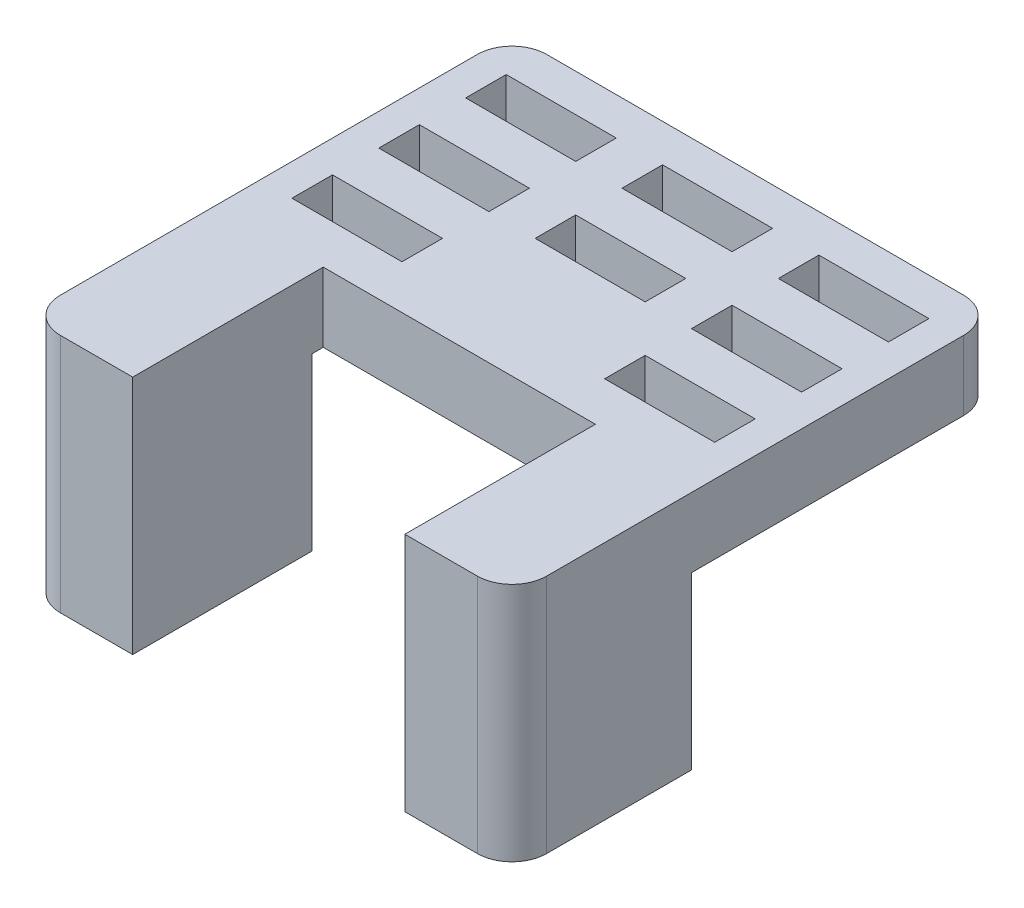
from build123d import *

# Parameters (mm, degrees)
SKETCH1_W            = 44
SKETCH1_H            = 44
BOSS_EXTRUDE1_DEPTH  = 6
CUT_EXTRUDE1_DEPTH   = 7
SKETCH4_W            = 44
SKETCH4_H            = 16.5
BOSS_EXTRUDE2_DEPTH  = 14.75
SKETCH5_W            = 23.5
SKETCH5_H            = 17.45
CUT_EXTRUDE2_DEPTH   = 21.75
FILLET1_R            = 3
SKETCH6_W            = 9.5
SKETCH6_H            = 3.5
CUT_EXTRUDE3_DEPTH   = 3.52
LPATTERN1_COUNT      = 3
LPATTERN1_PITCH      = 13.5
LPATTERN1_COUNT_DIR2 = 3
LPATTERN1_PITCH_DIR2 = 7.5
CUT_EXTRUDE5_REACH   = 22.75


with BuildPart() as part:
    # Sketch1 → Boss-Extrude1 (new body)
    with BuildSketch(Plane(origin=(0, 0, 0), x_dir=(1, 0, 0), z_dir=(0, 1, 0))):
        with Locations((22, 22)):
            Rectangle(SKETCH1_W, SKETCH1_H)
    extrude(amount=-BOSS_EXTRUDE1_DEPTH)

    # Sketch2 → Cut-Extrude1 (cut, through all)
    with BuildSketch(Plane(origin=(0, 0, 0), x_dir=(1, 0, 0), z_dir=(0, 1, 0))):
        with BuildLine():
            Line((5.475, 39.275), (11.525, 39.275))
            ThreePointArc((11.525, 39.275), (12.8, 38), (11.525, 36.725))
            Line((11.525, 36.725), (5.475, 36.725))
            ThreePointArc((5.475, 36.725), (4.2, 38), (5.475, 39.275))
        make_face()
        with BuildLine():
            Line((18.975, 39.275), (25.025, 39.275))
            ThreePointArc((25.025, 39.275), (26.3, 38), (25.025, 36.725))
            Line((25.025, 36.725), (18.975, 36.725))
            ThreePointArc((18.975, 36.725), (17.7, 38), (18.975, 39.275))
        make_face()
        with BuildLine():
            Line((32.475, 39.275), (38.525, 39.275))
            ThreePointArc((38.525, 39.275), (39.8, 38), (38.525, 36.725))
            Line((38.525, 36.725), (32.475, 36.725))
            ThreePointArc((32.475, 36.725), (31.2, 38), (32.475, 39.275))
        make_face()
        with BuildLine():
            Line((18.975, 31.775), (25.025, 31.775))
            ThreePointArc((25.025, 31.775), (26.3, 30.5), (25.025, 29.225))
            Line((25.025, 29.225), (18.975, 29.225))
            ThreePointArc((18.975, 29.225), (17.7, 30.5), (18.975, 31.775))
        make_face()
        with BuildLine():
            Line((32.475, 31.775), (38.525, 31.775))
            ThreePointArc((38.525, 31.775), (39.8, 30.5), (38.525, 29.225))
            Line((38.525, 29.225), (32.475, 29.225))
            ThreePointArc((32.475, 29.225), (31.2, 30.5), (32.475, 31.775))
        make_face()
        with BuildLine():
            Line((32.475, 24.275), (38.525, 24.275))
            ThreePointArc((38.525, 24.275), (39.8, 23), (38.525, 21.725))
            Line((38.525, 21.725), (32.475, 21.725))
            ThreePointArc((32.475, 21.725), (31.2, 23), (32.475, 24.275))
        make_face()
        with BuildLine():
            Line((5.475, 31.775), (11.525, 31.775))
            ThreePointArc((11.525, 31.775), (12.8, 30.5), (11.525, 29.225))
            Line((11.525, 29.225), (5.475, 29.225))
            ThreePointArc((5.475, 29.225), (4.2, 30.5), (5.475, 31.775))
        make_face()
        with BuildLine():
            Line((5.475, 24.275), (11.525, 24.275))
            ThreePointArc((11.525, 24.275), (12.8, 23), (11.525, 21.725))
            Line((11.525, 21.725), (5.475, 21.725))
            ThreePointArc((5.475, 21.725), (4.2, 23), (5.475, 24.275))
        make_face()
    extrude(amount=-CUT_EXTRUDE1_DEPTH, mode=Mode.SUBTRACT)

    # Sketch4 → Boss-Extrude2 (add)
    with BuildSketch(Plane.XZ.offset(6)):
        with Locations((22, -8.25)):
            Rectangle(SKETCH4_W, SKETCH4_H)
    extrude(amount=BOSS_EXTRUDE2_DEPTH)

    # Sketch5 → Cut-Extrude2 (cut, through all)
    with BuildSketch(Plane(origin=(0, 0, 0), x_dir=(1, 0, 0), z_dir=(0, 1, 0))):
        with Locations((22, 8.725)):
            Rectangle(SKETCH5_W, SKETCH5_H)
    extrude(amount=-CUT_EXTRUDE2_DEPTH, mode=Mode.SUBTRACT)

    # Fillet1
    fillet1_edges = [part.edges().sort_by_distance(p)[0] for p in [
        (0, -10.375, 0),
        (44, -10.375, 0),
        (44, -3, -44),
        (0, -3, -44),
    ]]
    fillet(fillet1_edges, radius=FILLET1_R)

    # Sketch6 → Cut-Extrude3 (cut)
    with BuildSketch(Plane(origin=(0, 0, 0), x_dir=(1, 0, 0), z_dir=(0, 1, 0))):
        with Locations((8.5, 38)):
            Rectangle(SKETCH6_W, SKETCH6_H)
    cut_extrude3 = extrude(amount=-CUT_EXTRUDE3_DEPTH, mode=Mode.SUBTRACT)

    # LPattern1: Cut-Extrude3 3 × 3, 1 skipped
    with Locations(*[(i * LPATTERN1_PITCH, 0, j * LPATTERN1_PITCH_DIR2) for i in range(LPATTERN1_COUNT) for j in range(LPATTERN1_COUNT_DIR2) if (i, j) not in ((0, 0), (1, 2))]):
        add(cut_extrude3, mode=Mode.SUBTRACT)

    # Sketch7 → Cut-Extrude5 (cut, up to next)
    with BuildSketch(Plane(origin=(0, 0, 0), x_dir=(1, 0, 0), z_dir=(0, 1, 0)), mode=Mode.PRIVATE) as cut_extrude5_sk1:
        with BuildLine():
            Line((10.25, 0), (10.25, 1))
            Line((10.25, 1), (4, 1))
            ThreePointArc((4, 1), (1.878679656, 1.878679656), (1, 4))
            Line((1, 4), (1, 40))
            ThreePointArc((1, 40), (1.878679656, 42.121320344), (4, 43))
            Line((4, 43), (40, 43))
            ThreePointArc((40, 43), (42.121320344, 42.121320344), (43, 40))
            Line((43, 40), (43, 4))
            ThreePointArc((43, 4), (42.121320344, 1.878679656), (40, 1))
            Line((40, 1), (33.75, 1))
            Line((33.75, 1), (33.75, 0))
            Line((33.75, 0), (41, 0))
            ThreePointArc((41, 0), (43.121320344, 0.878679656), (44, 3))
            Line((44, 3), (44, 41))
            ThreePointArc((44, 41), (43.121320344, 43.121320344), (41, 44))
            Line((41, 44), (3, 44))
            ThreePointArc((3, 44), (0.878679656, 43.121320344), (0, 41))
            Line((0, 41), (0, 3))
            ThreePointArc((0, 3), (0.878679656, 0.878679656), (3, 0))
            Line((3, 0), (10.25, 0))
        make_face()
    cut_extrude5_tool1 = extrude(cut_extrude5_sk1.sketch, amount=-CUT_EXTRUDE5_REACH, mode=Mode.PRIVATE) & part.part
    add(cut_extrude5_tool1.solids().sort_by_distance((6.625, 0, -0.622254))[0], mode=Mode.SUBTRACT)


solid = part.part
